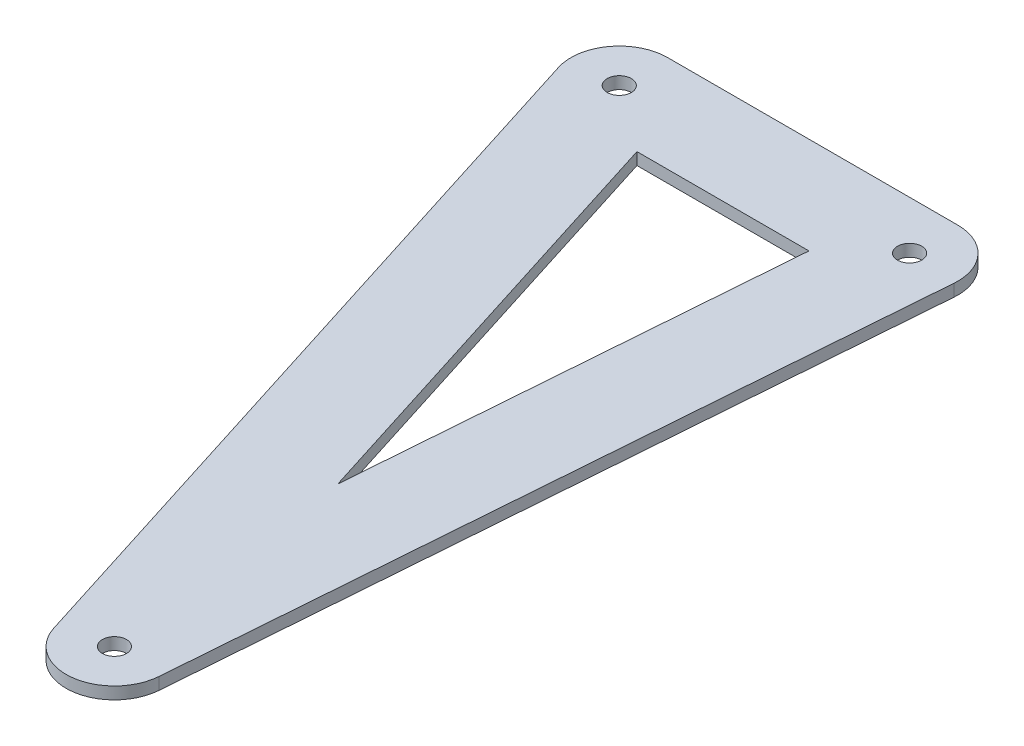
from build123d import *

# Parameters (mm, degrees)
SKETCH1_R           = 3.175
BOSS_EXTRUDE2_DEPTH = 3.175


with BuildPart() as part:
    # Sketch1 → Boss-Extrude2 (new body)
    with BuildSketch(Plane(origin=(0, 0, 0), x_dir=(1, 0, 0), z_dir=(0, 1, 0))):
        with BuildLine():
            ThreePointArc((88.862359447, -0.977063577), (85.519300066, 8.627899298), (76.2, 12.7))
            Line((76.2, 12.7), (0, 12.7))
            ThreePointArc((0, 12.7), (-10.244681695, 7.505764249), (-12.109317419, -3.828110715))
            Line((-12.109317419, -3.828110715), (49.140454024, -197.577189418))
            ThreePointArc((49.140454024, -197.577189418), (62.701866935, -206.365790583), (73.91213089, -194.726142279))
            Line((73.91213089, -194.726142279), (88.862359447, -0.977063577))
        make_face()
        Circle(SKETCH1_R, mode=Mode.SUBTRACT)
        Polygon((17.334338412, -12.7), (62.482279527, -12.7), (53.624378759, -127.494908088), align=None, mode=Mode.SUBTRACT)
        with Locations((61.249771443, -193.749078703)):
            Circle(SKETCH1_R, mode=Mode.SUBTRACT)
        with Locations((76.2, 0)):
            Circle(SKETCH1_R, mode=Mode.SUBTRACT)
    extrude(amount=BOSS_EXTRUDE2_DEPTH)


solid = part.part
